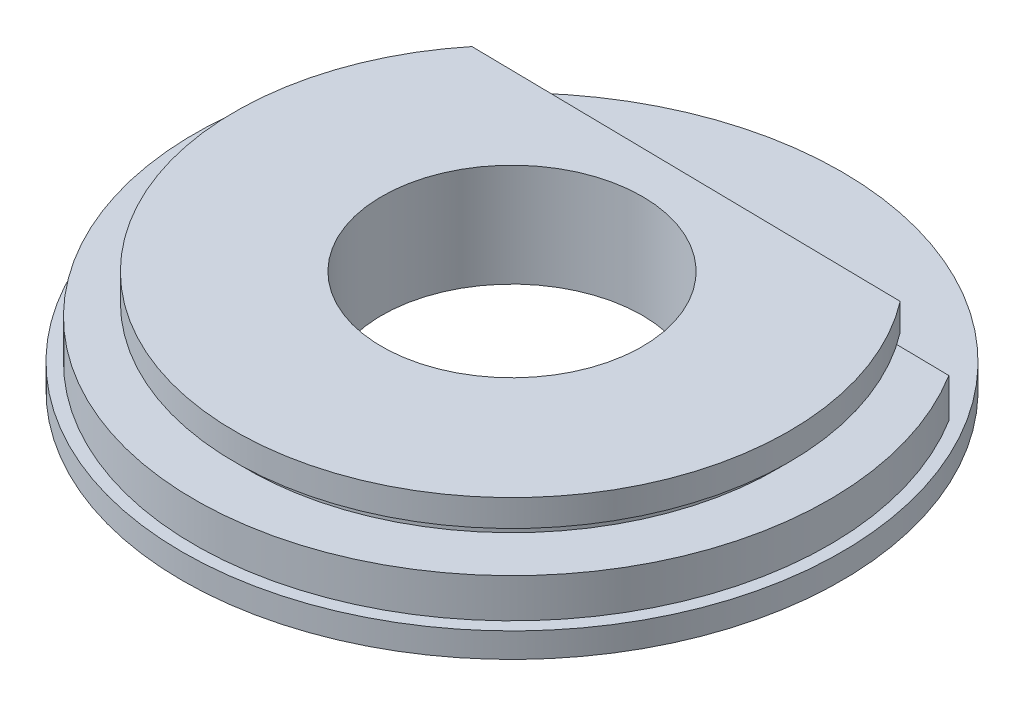
from build123d import *

# Parameters (mm, degrees)
CUT_EXTRUDE1_DEPTH = 9.5


with BuildPart() as part:
    # Sketch1 → Revolve1 (revolve)
    with BuildSketch(Plane.XY):
        Polygon((15.802589648, 0), (40, 0), (40, 3), (38.5, 3), (38.5, 7.75), (32.113475553, 7.75), (32.113475553, 9.25), (33.613475553, 9.25), (33.613475553, 12.5), (15.802589648, 12.5), align=None)
    revolve(axis=Axis((0, 0, 0), (0, 1, 0)))

    # Sketch2 → Cut-Extrude1 (cut)
    with BuildSketch(Plane(origin=(0, 12.5, 0), x_dir=(1, 0, 0), z_dir=(0, 1, 0))):
        with BuildLine():
            Line((-32.06723123, 21.305930659), (32.696608404, 20.326873809))
            ThreePointArc((32.696608404, 20.326873809), (0.581951017, 38.495601476), (-32.06723123, 21.305930659))
        make_face()
    extrude(amount=-CUT_EXTRUDE1_DEPTH, mode=Mode.SUBTRACT)


solid = part.part
